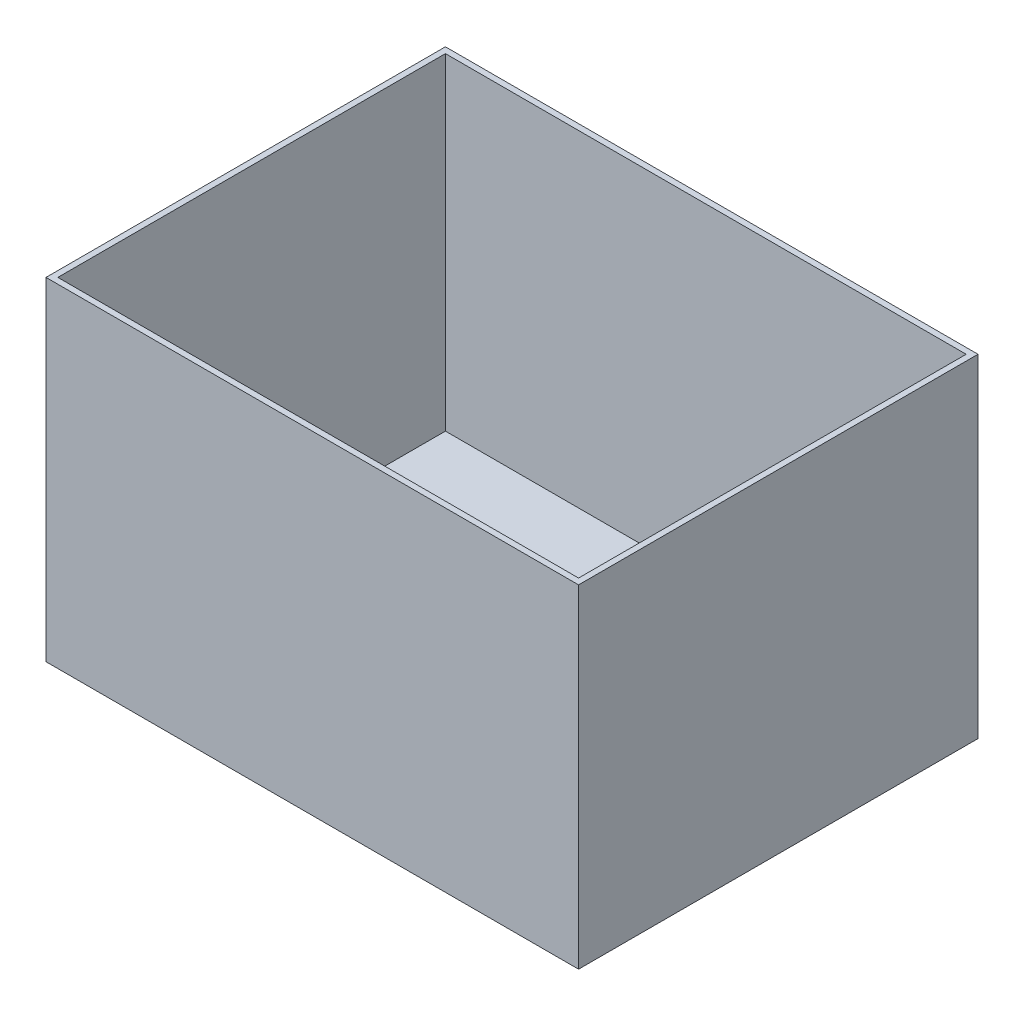
from build123d import *

# Parameters (mm, degrees)
SALIENTE_EXTRUIR1_DEPTH      = 135
SALIENTE_EXTRUIR1_DEPTH_BACK = 135
CROQUIS1_W                   = 360
CROQUIS1_H                   = 225
VACIADO1_T                   = -4


with BuildPart() as part:
    # Croquis1 → Saliente-Extruir1 (new, two sides: drawn at the far end of the back side and taken through both)
    with BuildSketch(Plane.XY.offset(-SALIENTE_EXTRUIR1_DEPTH_BACK)):
        Rectangle(CROQUIS1_W, CROQUIS1_H)
    extrude(amount=SALIENTE_EXTRUIR1_DEPTH + SALIENTE_EXTRUIR1_DEPTH_BACK)

    # Vaciado1
    vaciado1_openings = [part.faces().sort_by_distance(p)[0] for p in [
        (0, 112.5, 0),
    ]]
    offset(amount=VACIADO1_T, openings=vaciado1_openings, kind=Kind.INTERSECTION)


solid = part.part
